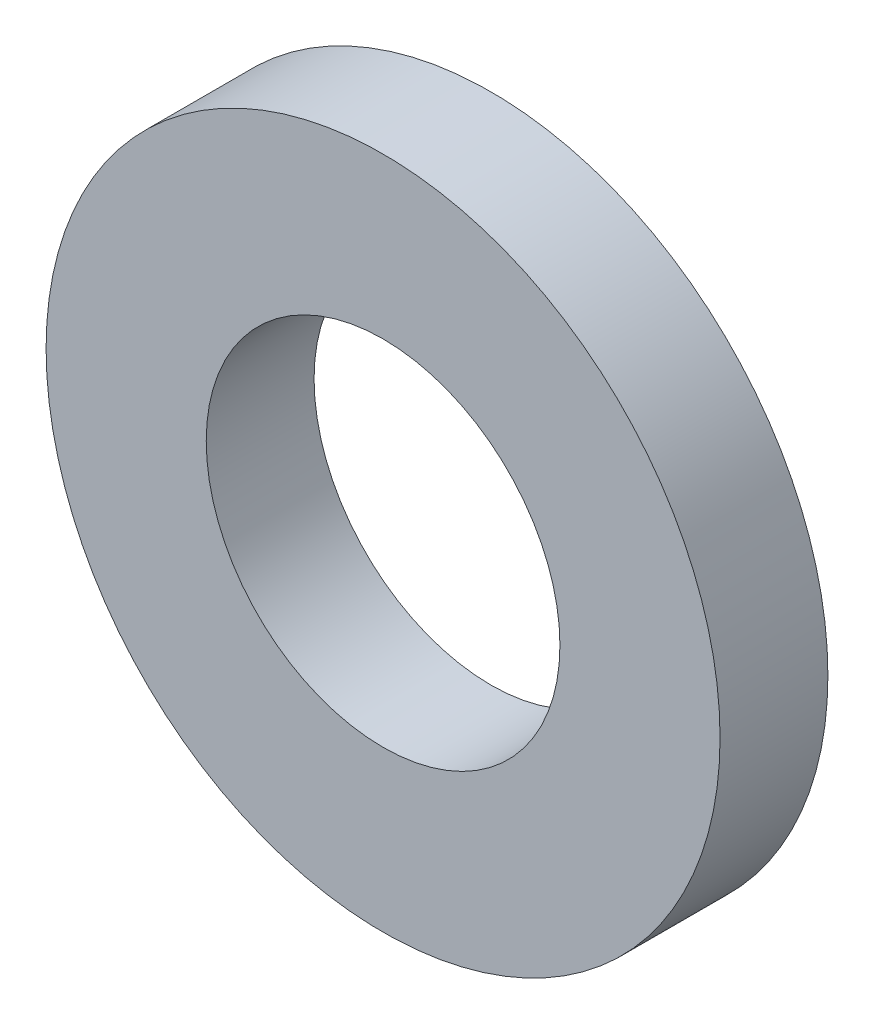
from build123d import *

# Parameters (mm, degrees)
SKETCH1_R      = 3.96875
SKETCH1_R_2    = 2.0828
EXTRUDE1_DEPTH = 1.27


with BuildPart() as part:
    # Sketch1 → Extrude1 (new body)
    with BuildSketch(Plane.XY):
        Circle(SKETCH1_R)
        Circle(SKETCH1_R_2, mode=Mode.SUBTRACT)
    extrude(amount=-EXTRUDE1_DEPTH)


solid = part.part
